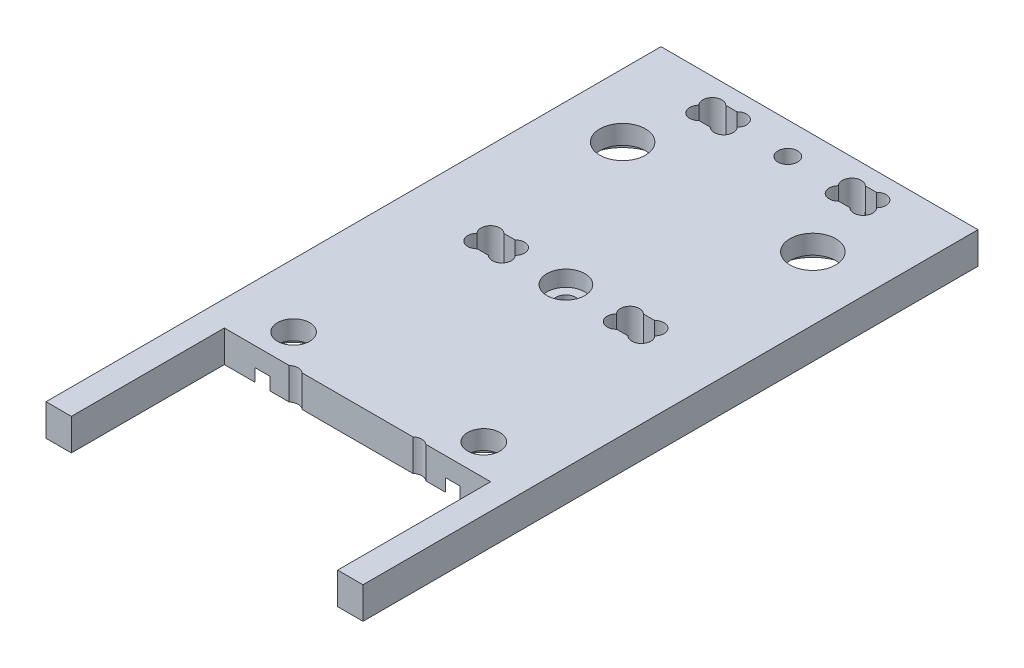
from build123d import *

# Parameters (mm, degrees)
CROQUIS1_W              = 50
CROQUIS1_H              = 97
SALIENTE_EXTRUIR1_DEPTH = 5
CROQUIS2_R              = 3.6
CROQUIS2_R_2            = 2.55
CORTAR_EXTRUIR2_DEPTH   = 6
CROQUIS4_R              = 6
CROQUIS4_R_2            = 5.05
CORTAR_EXTRUIR3_DEPTH   = 2
CROQUIS5_R              = 1.55
CROQUIS5_W              = 6
CROQUIS5_H              = 4.2
CORTAR_EXTRUIR4_DEPTH   = 6
CORTAR_EXTRUIR6_DEPTH   = 6
CROQUIS14_R             = 3
CORTAR_EXTRUIR9_DEPTH   = 2.5
CROQUIS18_R             = 10.5
CROQUIS18_R_2           = 1.525
CORTAR_EXTRUIR10_DEPTH  = 6
CROQUIS20_W             = 42
CROQUIS20_H             = 25.956058456
CORTAR_EXTRUIR11_DEPTH  = 6


with BuildPart() as part:
    # Croquis1 → Saliente-Extruir1 (new body)
    with BuildSketch(Plane(origin=(0, 0, 0), x_dir=(1, 0, 0), z_dir=(0, 1, 0))):
        Rectangle(CROQUIS1_W, CROQUIS1_H)
    extrude(amount=SALIENTE_EXTRUIR1_DEPTH)

    # Croquis2 → Cortar-Extruir2 (cut, through all)
    with BuildSketch(Plane(origin=(0, 5, 0), x_dir=(1, 0, 0), z_dir=(0, 1, 0))):
        with Locations((-15, 32.45)):
            Circle(CROQUIS2_R)
        with Locations((15, 32.45)):
            Circle(CROQUIS2_R)
        with Locations((15, -19.45)):
            Circle(CROQUIS2_R_2)
        with Locations((-15, -19.45)):
            Circle(CROQUIS2_R_2)
    extrude(amount=-CORTAR_EXTRUIR2_DEPTH, mode=Mode.SUBTRACT)

    # Croquis4 → Cortar-Extruir3 (cut)
    with BuildSketch(Plane.XZ):
        with Locations((15, -32.45)):
            Circle(CROQUIS4_R)
        with Locations((-15, -32.45)):
            Circle(CROQUIS4_R)
        with Locations((-15, 19.45)):
            Circle(CROQUIS4_R_2)
        with Locations((15, 19.45)):
            Circle(CROQUIS4_R_2)
    extrude(amount=-CORTAR_EXTRUIR3_DEPTH, mode=Mode.SUBTRACT)

    # Croquis5 → Cortar-Extruir4 (cut, through all)
    with BuildSketch(Plane(origin=(0, 5, 0), x_dir=(1, 0, 0), z_dir=(0, 1, 0))):
        with Locations((0, 43.5)):
            Circle(CROQUIS5_R)
        with Locations((-11, 43.5)):
            Rectangle(CROQUIS5_W, CROQUIS5_H)
        with Locations((11, 43.5)):
            Rectangle(CROQUIS5_W, CROQUIS5_H)
    cortar_extruir4 = extrude(amount=-CORTAR_EXTRUIR4_DEPTH, mode=Mode.SUBTRACT)

    # Croquis8 → Cortar-Extruir6 (cut, through all)
    with BuildSketch(Plane(origin=(0, 5, 0), x_dir=(1, 0, 0), z_dir=(0, 1, 0))):
        with BuildLine():
            Line((-11.878679656, 45.6), (-10.121320344, 45.6))
            ThreePointArc((-10.121320344, 45.6), (-8.010608171, 45.610503119), (-7.979099854, 43.5))
            ThreePointArc((-7.979099854, 43.5), (-8.010608171, 41.389496881), (-10.121320344, 41.4))
            Line((-10.121320344, 41.4), (-11.878679656, 41.4))
            ThreePointArc((-11.878679656, 41.4), (-13.989391829, 41.389496881), (-14.020900146, 43.5))
            ThreePointArc((-14.020900146, 43.5), (-13.989391829, 45.610503119), (-11.878679656, 45.6))
        make_face()
        with BuildLine():
            Line((10.121320344, 41.4), (11.878679656, 41.4))
            ThreePointArc((11.878679656, 41.4), (13.989391829, 41.389496881), (14.020900146, 43.5))
            ThreePointArc((14.020900146, 43.5), (13.989391829, 45.610503119), (11.878679656, 45.6))
            Line((11.878679656, 45.6), (10.121320344, 45.6))
            ThreePointArc((10.121320344, 45.6), (8.010608171, 45.610503119), (7.979099854, 43.5))
            ThreePointArc((7.979099854, 43.5), (8.010608171, 41.389496881), (10.121320344, 41.4))
        make_face()
    cortar_extruir6 = extrude(amount=-CORTAR_EXTRUIR6_DEPTH, mode=Mode.SUBTRACT)

    # Simetría1: Cortar-Extruir4, Cortar-Extruir6 across plane
    add(cortar_extruir4.mirror(Plane.XY.offset(-26)), mode=Mode.SUBTRACT)
    add(cortar_extruir6.mirror(Plane.XY.offset(-26)), mode=Mode.SUBTRACT)

    # Croquis14 → Cortar-Extruir9 (cut)
    with BuildSketch(Plane(origin=(0, 5, 0), x_dir=(1, 0, 0), z_dir=(0, 1, 0))):
        with Locations((0, 8.5)):
            Circle(CROQUIS14_R)
    extrude(amount=-CORTAR_EXTRUIR9_DEPTH, mode=Mode.SUBTRACT)

    # Croquis18 → Cortar-Extruir10 (cut, through all)
    with BuildSketch(Plane(origin=(0, 5, 0), x_dir=(1, 0, 0), z_dir=(0, 1, 0))):
        with Locations((0, -35.5)):
            Circle(CROQUIS18_R)
        with Locations((9.75, -45.5)):
            Circle(CROQUIS18_R_2)
        with Locations((-9.75, -45.5)):
            Circle(CROQUIS18_R_2)
        with Locations((9.75, -25.5)):
            Circle(CROQUIS18_R_2)
        with Locations((-9.75, -25.5)):
            Circle(CROQUIS18_R_2)
    extrude(amount=-CORTAR_EXTRUIR10_DEPTH, mode=Mode.SUBTRACT)

    # Croquis20 → Cortar-Extruir11 (cut, through all)
    with BuildSketch(Plane.XZ):
        with Locations((0, 37.343359165)):
            Rectangle(CROQUIS20_W, CROQUIS20_H)
    extrude(amount=-CORTAR_EXTRUIR11_DEPTH, mode=Mode.SUBTRACT)


solid = part.part
